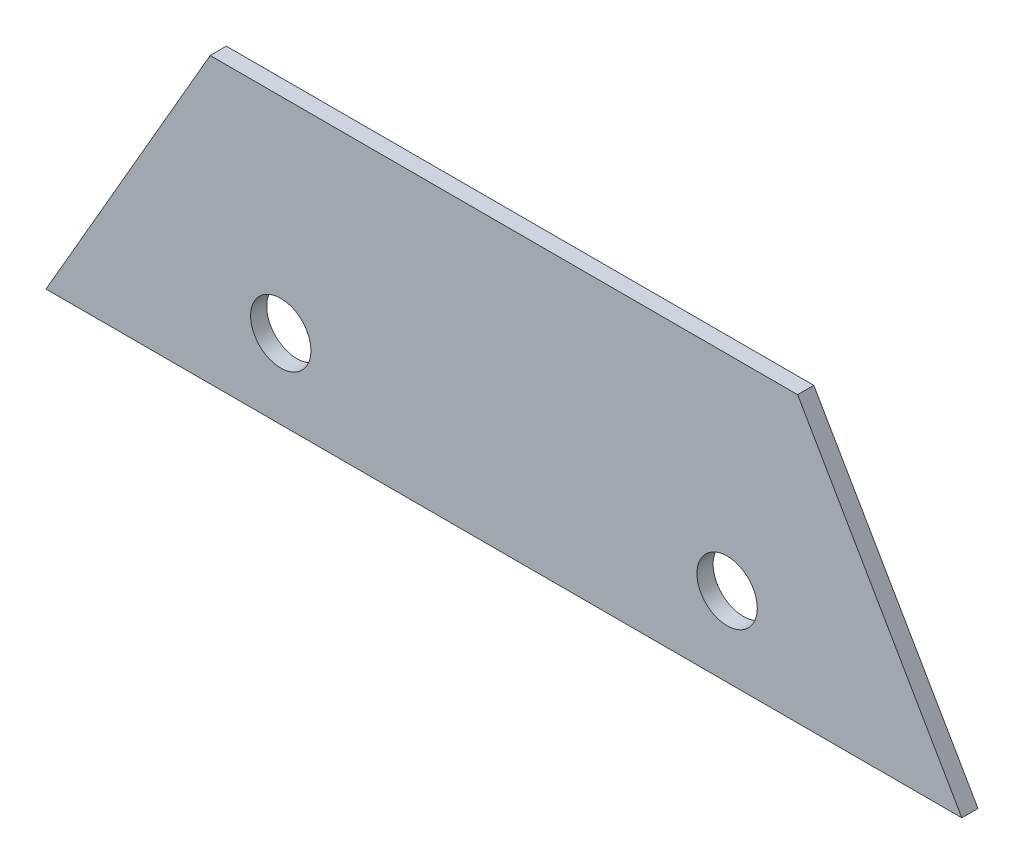
from build123d import *

# Parameters (mm, degrees)
BOSS_EXTRUDE1_DEPTH = 11.90625
SKETCH2_R           = 22.225
CUT_EXTRUDE1_DEPTH  = 12.90625


with BuildPart() as part:
    # Sketch1 → Boss-Extrude1 (new body)
    with BuildSketch(Plane.XY):
        Polygon((-337.114930678, -583.900187925), (-216.238948081, -374.536844651), (216.238948081, -374.536844651), (337.114930678, -583.900187925), align=None)
    extrude(amount=-BOSS_EXTRUDE1_DEPTH)

    # Sketch2 → Cut-Extrude1 (cut, through all)
    with BuildSketch(Plane.XY):
        with Locations((-164.309496882, -525.607187925)):
            Circle(SKETCH2_R)
        with Locations((164.309496882, -525.607187925)):
            Circle(SKETCH2_R)
    extrude(amount=-CUT_EXTRUDE1_DEPTH, mode=Mode.SUBTRACT)


solid = part.part
